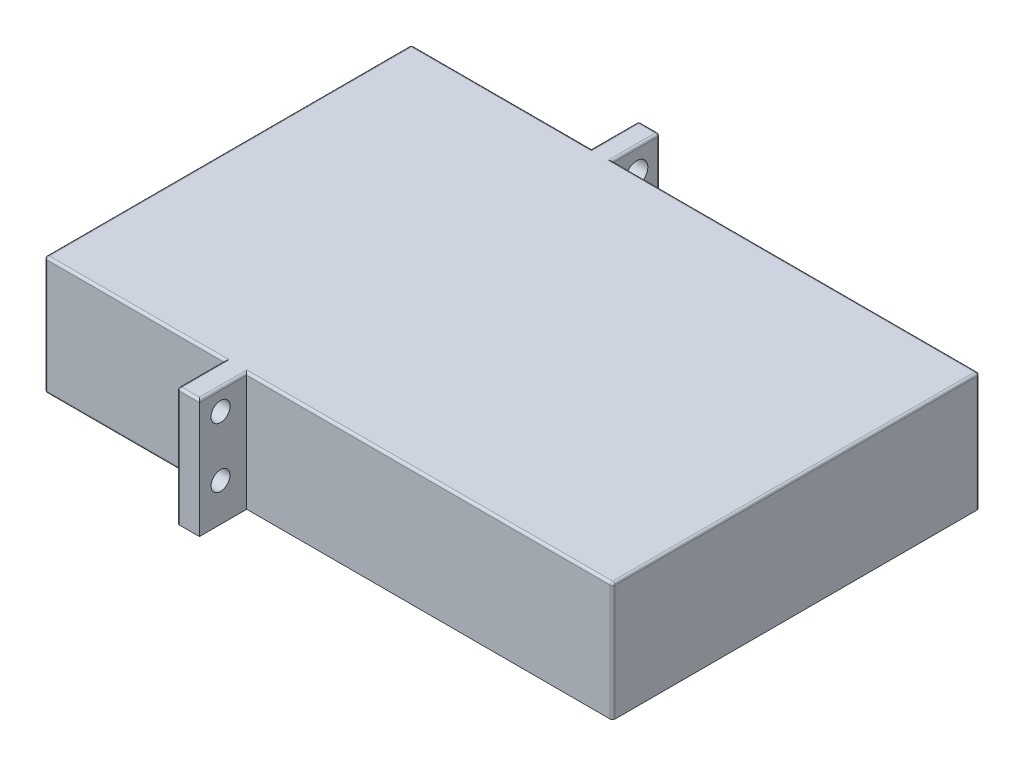
from build123d import *

# Parameters (mm, degrees)
SKETCH_1_W          = 48
SKETCH_1_H          = 10
EXTRUDE_1_DEPTH     = 31
SKETCH_4_W          = 1.788999432
SKETCH_4_H          = 10
EXTRUDE_2_DEPTH     = 4
SKETCH_14_W         = 1.871956719
SKETCH_14_H         = 10
EXTRUDE_4_DEPTH     = 4
SKETCH_15_R         = 3.665821214
EXTRUDE_5_DEPTH     = 0.5
SKETCH_16_R         = 3.013049761
EXTRUDE_6_DEPTH     = 0.3
SKETCH_17_R         = 1.236050747
EXTRUDE_8_DEPTH     = 2
SKETCH_22_R         = 0.88346166
SKETCH_22_R_2       = 0.936856128
CUT_EXTRUDE_1_DEPTH = 5
SKETCH_23_R         = 0.805014206
SKETCH_23_R_2       = 0.796081263
CUT_EXTRUDE_2_DEPTH = 5
FILLET_3_R          = 0.2
FILLET_4_R          = 0.2
FILLET_5_R          = 0.2
FILLET_6_R          = 0.2
FILLET_7_R          = 0.2
FILLET_8_R          = 0.2
FILLET_9_R          = 0.2
FILLET_10_R         = 0.2


with BuildPart() as part:
    # 草图1 → 凸台-拉伸1 (new body)
    with BuildSketch(Plane.XY):
        with Locations((11.931034483, 24.804987121)):
            Rectangle(SKETCH_1_W, SKETCH_1_H)
    extrude(amount=EXTRUDE_1_DEPTH)

    # 草图4 → 凸台-拉伸2 (add)
    with BuildSketch(Plane(origin=(0, 0, 0), x_dir=(-1, 0, 0), z_dir=(0, 0, -1))):
        with Locations((-4.036534767, 24.804987121)):
            Rectangle(SKETCH_4_W, SKETCH_4_H)
    extrude(amount=EXTRUDE_2_DEPTH)

    # 草图14 → 凸台-拉伸4 (add)
    with BuildSketch(Plane.XY.offset(31)):
        with Locations((4.078013411, 24.804987121)):
            Rectangle(SKETCH_14_W, SKETCH_14_H)
    extrude(amount=EXTRUDE_4_DEPTH)

    # 草图15 → 凸台-拉伸5 (add)
    with BuildSketch(Plane.ZY.offset(12.068965517)):
        with Locations((11.958075482, 25.418989077)):
            Circle(SKETCH_15_R)
    extrude(amount=EXTRUDE_5_DEPTH)

    # 草图16 → 凸台-拉伸6 (add)
    with BuildSketch(Plane.ZY.offset(12.568965517)):
        with Locations((11.958075482, 25.418989077)):
            Circle(SKETCH_16_R)
    extrude(amount=EXTRUDE_6_DEPTH)

    # 草图17 → 凸台-拉伸8 (add)
    with BuildSketch(Plane.ZY.offset(12.868965517)):
        with Locations((11.895385931, 25.638311879)):
            Circle(SKETCH_17_R)
    extrude(amount=EXTRUDE_8_DEPTH)

    # 草图22 → 切除-拉伸1 (cut)
    with BuildSketch(Plane.ZY.offset(-3.142035051)):
        with Locations((-2.041924518, 23.020543935)):
            Circle(SKETCH_22_R)
        with Locations((-2.041924518, 27.817434219)):
            Circle(SKETCH_22_R_2)
    extrude(amount=-CUT_EXTRUDE_1_DEPTH, mode=Mode.SUBTRACT)

    # 草图23 → 切除-拉伸2 (cut)
    with BuildSketch(Plane.ZY.offset(-3.142035051)):
        with Locations((33.213635659, 28.067477757)):
            Circle(SKETCH_23_R)
        with Locations((33.213635659, 23.020543935)):
            Circle(SKETCH_23_R_2)
    extrude(amount=-CUT_EXTRUDE_2_DEPTH, mode=Mode.SUBTRACT)

    # 圆角3
    fillet_3_edges = [part.edges().sort_by_distance(p)[0] for p in [
        (35.931034483, 29.804987121, 15.5),
    ]]
    fillet(fillet_3_edges, radius=FILLET_3_R)

    # 圆角4
    fillet_4_edges = [part.edges().sort_by_distance(p)[0] for p in [
        (-4.463465233, 29.804987121, 0),
        (35.931034483, 24.704987121, 0),
        (20.331034483, 29.804987121, 0),
        (35.872455839, 29.746408477, 0),
    ]]
    fillet(fillet_4_edges, radius=FILLET_4_R)

    # 圆角5
    fillet_5_edges = [part.edges().sort_by_distance(p)[0] for p in [
        (4.931034483, 29.804987121, -2),
        (3.142035051, 29.804987121, -2),
    ]]
    fillet(fillet_5_edges, radius=FILLET_5_R)

    # 圆角6
    fillet_6_edges = [part.edges().sort_by_distance(p)[0] for p in [
        (4.931034483, 24.704987121, -4),
        (4.036534767, 29.804987121, -4),
        (3.200613695, 29.746408477, -4),
        (4.872455839, 29.746408477, -4),
        (35.931034483, 24.704987121, 31),
        (3.142035051, 24.704987121, -4),
        (20.372513126, 29.804987121, 31),
        (35.872455839, 29.746408477, 31),
    ]]
    fillet(fillet_6_edges, radius=FILLET_6_R)

    # 圆角7
    fillet_7_edges = [part.edges().sort_by_distance(p)[0] for p in [
        (4.07801341, 29.804987121, 35),
        (5.01399177, 29.804987121, 33),
    ]]
    fillet(fillet_7_edges, radius=FILLET_7_R)

    # 圆角8
    fillet_8_edges = [part.edges().sort_by_distance(p)[0] for p in [
        (3.142035051, 24.704987121, 35),
        (3.142035051, 29.804987121, 32.9),
        (3.142035051, 29.746408477, 34.941421356),
        (-4.463465233, 29.804987121, 31),
    ]]
    fillet(fillet_8_edges, radius=FILLET_8_R)

    # 圆角9
    fillet_9_edges = [part.edges().sort_by_distance(p)[0] for p in [
        (-12.068965517, 24.704987121, 31),
        (-12.068965517, 29.804987121, 15.5),
        (-12.068965517, 29.746408477, 30.941421356),
        (-12.068965517, 24.704987121, 0),
        (-12.068965517, 29.746408477, 0.058578644),
    ]]
    fillet(fillet_9_edges, radius=FILLET_9_R)

    # 圆角10
    fillet_10_edges = [part.edges().sort_by_distance(p)[0] for p in [
        (-12.068965517, 19.804987121, 15.5),
        (-4.363465233, 19.804987121, 31),
        (-4.363465233, 19.804987121, 0),
        (-12.010386873, 19.804987121, 30.941421356),
        (-12.010386873, 19.804987121, 0.058578644),
    ]]
    fillet(fillet_10_edges, radius=FILLET_10_R)


solid = part.part
